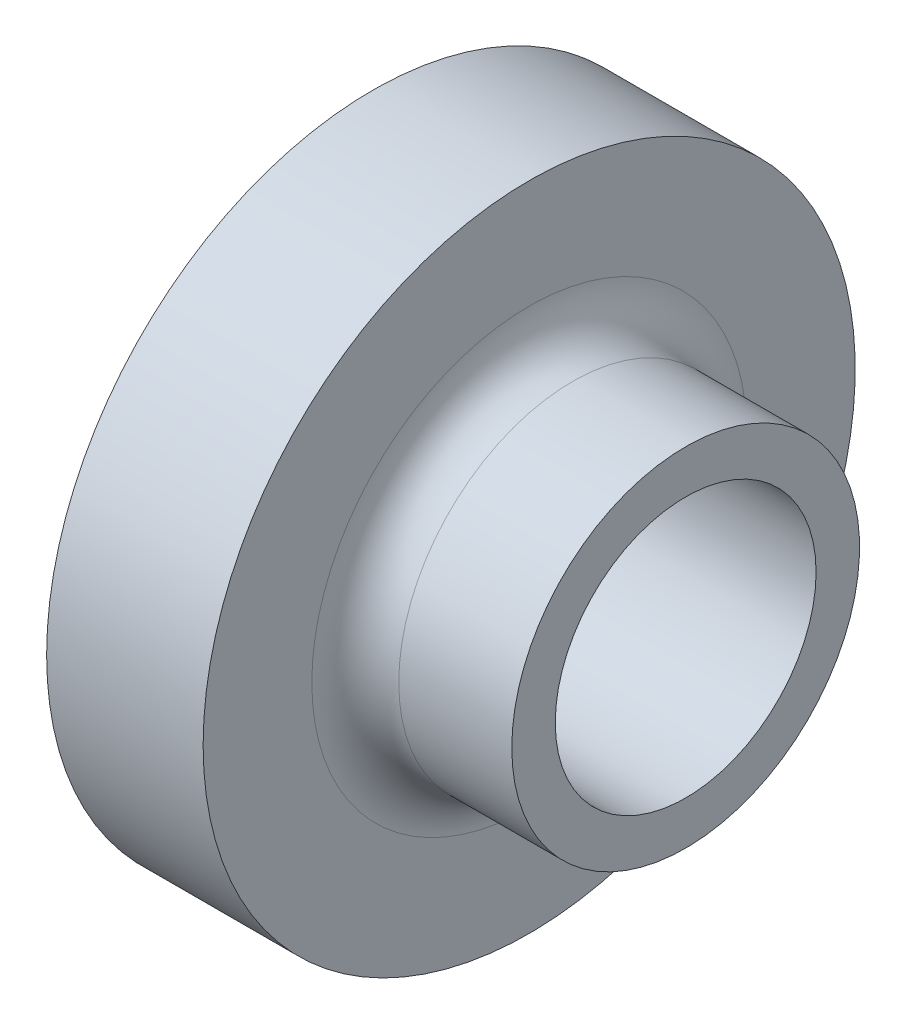
from build123d import *

# Parameters (mm, degrees)
RADYUS1_R = 5


with BuildPart() as part:
    # Çizim1 → Döndür1 (revolve)
    with BuildSketch(Plane.XY):
        Polygon((0, 37.5), (18, 37.5), (18, 20), (36, 20), (36, 15), (0, 15), align=None)
    revolve(axis=Axis((0, 0, 0), (1, 0, 0)))

    # Radyus1
    radyus1_edges = [part.edges().sort_by_distance(p)[0] for p in [
        (18, -20, 0),
    ]]
    fillet(radyus1_edges, radius=RADYUS1_R)


solid = part.part
